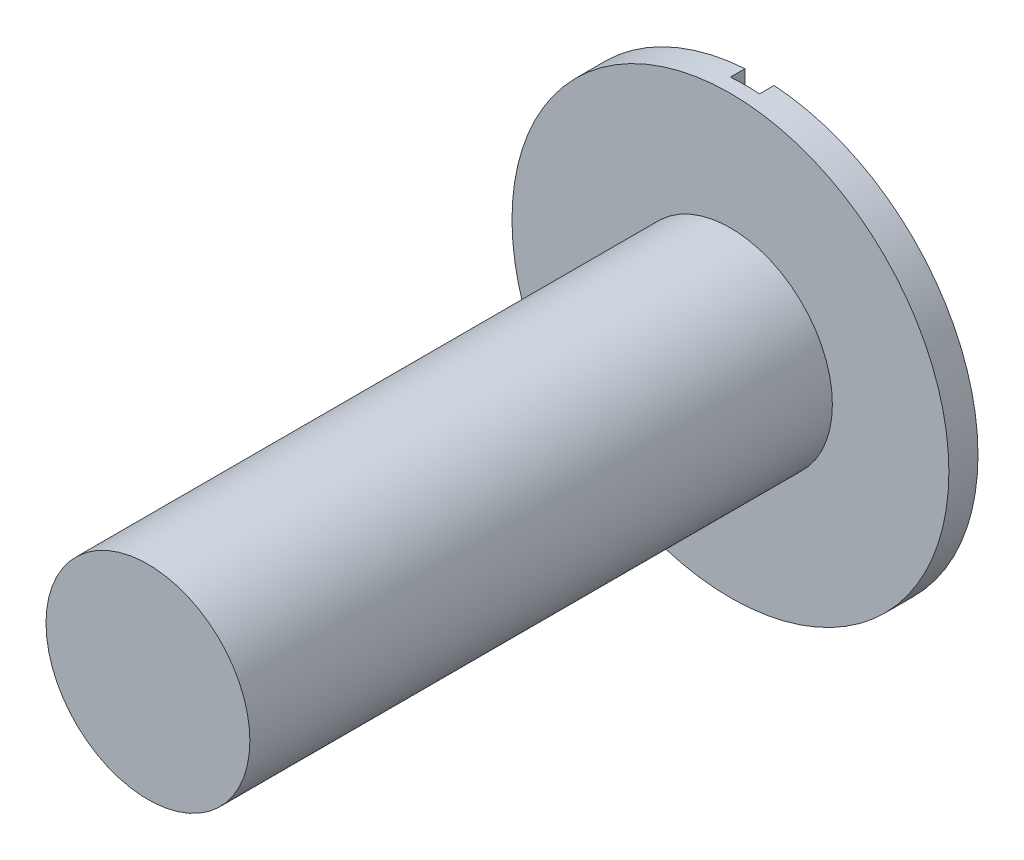
from build123d import *

# Parameters (mm, degrees)
CROQUIS1_R              = 0.75
SALIENTE_EXTRUIR1_DEPTH = 0.1
CROQUIS2_R              = 0.35
SALIENTE_EXTRUIR2_DEPTH = 2
CROQUIS3_W              = 0.1
CROQUIS3_H              = 1.62143155
CORTAR_EXTRUIR1_DEPTH   = 0.05


with BuildPart() as part:
    # Croquis1 → Saliente-Extruir1 (new body)
    with BuildSketch(Plane.XY):
        Circle(CROQUIS1_R)
    extrude(amount=SALIENTE_EXTRUIR1_DEPTH)

    # Croquis2 → Saliente-Extruir2 (add)
    with BuildSketch(Plane.XY.offset(0.1)):
        Circle(CROQUIS2_R)
    extrude(amount=SALIENTE_EXTRUIR2_DEPTH)

    # Croquis3 → Cortar-Extruir1 (cut)
    with BuildSketch(Plane(origin=(0, 0, 0), x_dir=(-1, 0, 0), z_dir=(0, 0, -1))):
        Rectangle(CROQUIS3_W, CROQUIS3_H)
    extrude(amount=-CORTAR_EXTRUIR1_DEPTH, mode=Mode.SUBTRACT)


solid = part.part
